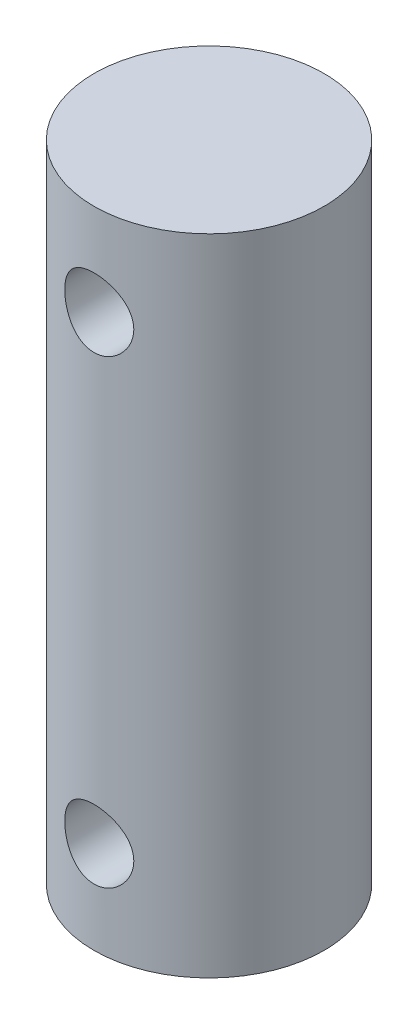
from build123d import *

# Parameters (mm, degrees)
SKETCH1_R               = 4.9995
BOSS_EXTRUDE1_DEPTH     = 28
SKETCH2_R               = 1.5
CUT_EXTRUDE1_DEPTH      = 5.9995
CUT_EXTRUDE1_DEPTH_BACK = 5.9995


with BuildPart() as part:
    # Sketch1 → Boss-Extrude1 (new body)
    with BuildSketch(Plane(origin=(0, 0, 0), x_dir=(1, 0, 0), z_dir=(0, 1, 0))):
        Circle(SKETCH1_R)
    extrude(amount=BOSS_EXTRUDE1_DEPTH)

    # Sketch2 → Cut-Extrude1 (cut, two sides)
    with BuildSketch(Plane.XY) as cut_extrude1_sk:
        with Locations((0, 4)):
            Circle(SKETCH2_R)
        with Locations((0, 24)):
            Circle(SKETCH2_R)
    extrude(amount=CUT_EXTRUDE1_DEPTH, mode=Mode.SUBTRACT)
    extrude(cut_extrude1_sk.sketch, amount=-CUT_EXTRUDE1_DEPTH_BACK, mode=Mode.SUBTRACT)


solid = part.part
